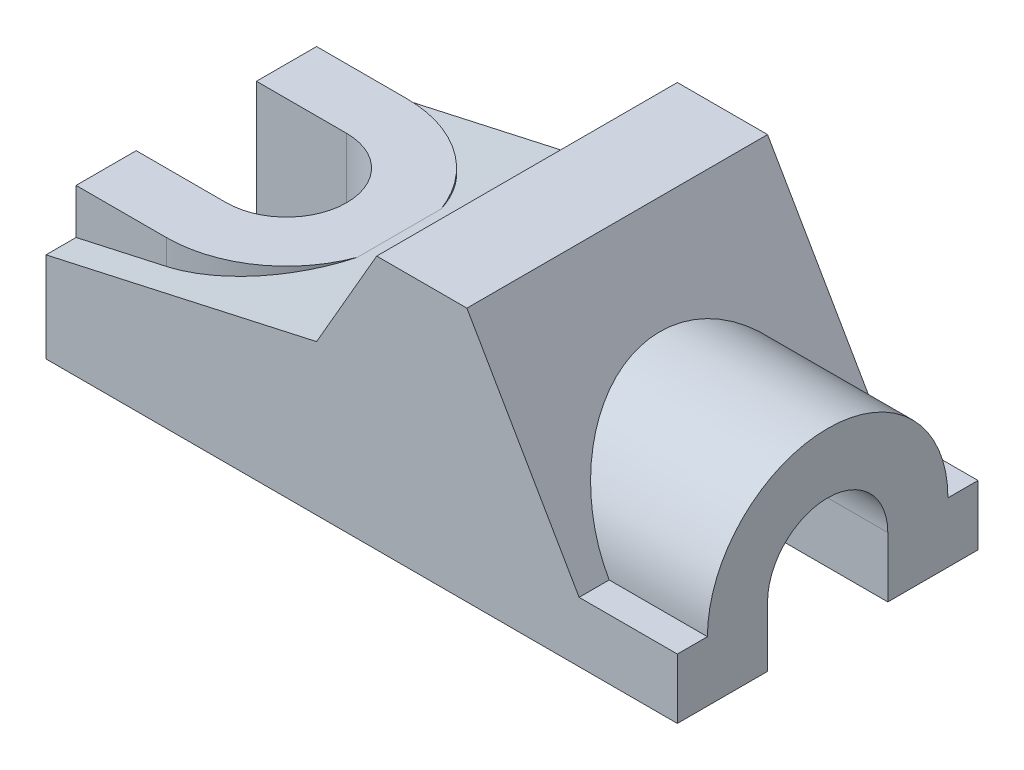
from build123d import *
from build123d.topology import SkipClean

# Parameters (mm, degrees)
BOSS_EXTRUDE1_DEPTH = 31.75
BOSS_EXTRUDE2_REACH = 149.238
CUT_EXTRUDE1_DEPTH  = 53.975
BOSS_EXTRUDE4_REACH = 142.024
CUT_EXTRUDE2_DEPTH  = 141.024339402


with BuildPart() as part:
    # Sketch1 → Boss-Extrude1 (new, symmetric)
    with BuildSketch(Plane.XY):
        Polygon((0, 0), (133.35, 0), (133.35, 12.7), (112.598522628, 12.7), (88.9, 53.747045256), (69.85, 53.747045256), (57.15, 31.75), (0, 19.05), align=None)
    extrude(amount=BOSS_EXTRUDE1_DEPTH, both=True)

    # Boss-Extrude2: up to this plane
    boss_extrude2_end = Plane(origin=(88.9, 53.747045256, 31.75), z_dir=(-0.8660254037844364, -0.5000000000000041, 0))
    # Sketch2 → Boss-Extrude2 (add, up to the surface)
    with BuildSketch(Plane(origin=(133.35, 0, 0), x_dir=(0, 0, -1), z_dir=(1, 0, 0)), mode=Mode.PRIVATE) as boss_extrude2_sk1:
        with BuildLine():
            Line((-12.7, 0), (-12.7, 12.7))
            ThreePointArc((-12.7, 12.7), (0, 25.4), (12.7, 12.7))
            Line((12.7, 12.7), (12.7, 0))
            Line((12.7, 0), (25.4, 0))
            Line((25.4, 0), (25.4, 12.7))
            ThreePointArc((25.4, 12.7), (0, 38.1), (-25.4, 12.7))
            Line((-25.4, 12.7), (-25.4, 0))
            Line((-25.4, 0), (-12.7, 0))
        make_face()
    boss_extrude2_tool1 = split(extrude(boss_extrude2_sk1.sketch, amount=-BOSS_EXTRUDE2_REACH, mode=Mode.PRIVATE), bisect_by=boss_extrude2_end, keep=Keep.BOTH, mode=Mode.PRIVATE)
    add(boss_extrude2_tool1.solids().sort_by_distance((133.35, 6.35, 24.765))[0])

    # Sketch2_3 → Cut-Extrude1 (cut)
    with BuildSketch(Plane(origin=(133.35, 0, 0), x_dir=(0, 0, -1), z_dir=(1, 0, 0))):
        with BuildLine():
            Line((-12.7, 0), (12.7, 0))
            Line((12.7, 0), (12.7, 12.7))
            ThreePointArc((12.7, 12.7), (0, 25.4), (-12.7, 12.7))
            Line((-12.7, 12.7), (-12.7, 0))
        make_face()
    extrude(amount=-CUT_EXTRUDE1_DEPTH, mode=Mode.SUBTRACT)

    # Boss-Extrude4: up to this face of the body (flat: up to its plane)
    boss_extrude4_end = Plane(part.part.faces().sort_by_distance((28.575, 25.4, 0))[0])
    # Sketch4 → Boss-Extrude4 (add, up to the picked face)
    with BuildSketch(Plane(origin=(0, 28.575, 0), x_dir=(-1, 0, 0), z_dir=(0, -1, 0)), mode=Mode.PRIVATE) as boss_extrude4_sk1:
        with BuildLine():
            ThreePointArc((-19.05, -12.7), (-31.75, 0), (-19.05, 12.7))
            Line((-19.05, 12.7), (0, 12.7))
            Line((0, 12.7), (0, 25.4))
            Line((0, 25.4), (-19.05, 25.4))
            ThreePointArc((-19.05, 25.4), (-44.45, 0), (-19.05, -25.4))
            Line((-19.05, -25.4), (0, -25.4))
            Line((0, -25.4), (0, -12.7))
            Line((0, -12.7), (-19.05, -12.7))
        make_face()
    boss_extrude4_tool1 = split(extrude(boss_extrude4_sk1.sketch, amount=BOSS_EXTRUDE4_REACH, mode=Mode.PRIVATE), bisect_by=boss_extrude4_end, keep=Keep.BOTH, mode=Mode.PRIVATE)
    add(boss_extrude4_tool1.solids().sort_by(Axis((32.425014, 28.575, 0), (0, -1, 0)))[0])

    # Sketch4_3 → Cut-Extrude2 (cut, through all)
    with SkipClean():  # the faces are left unmerged after this step: merging them gives an invalid solid
        with BuildSketch(Plane(origin=(0, 28.575, 0), x_dir=(-1, 0, 0), z_dir=(0, -1, 0))):
            with BuildLine():
                Line((0, -12.7), (0, 12.7))
                Line((0, 12.7), (-19.05, 12.7))
                ThreePointArc((-19.05, 12.7), (-31.75, 0), (-19.05, -12.7))
                Line((-19.05, -12.7), (0, -12.7))
            make_face()
        extrude(amount=CUT_EXTRUDE2_DEPTH, mode=Mode.SUBTRACT)


solid = part.part
